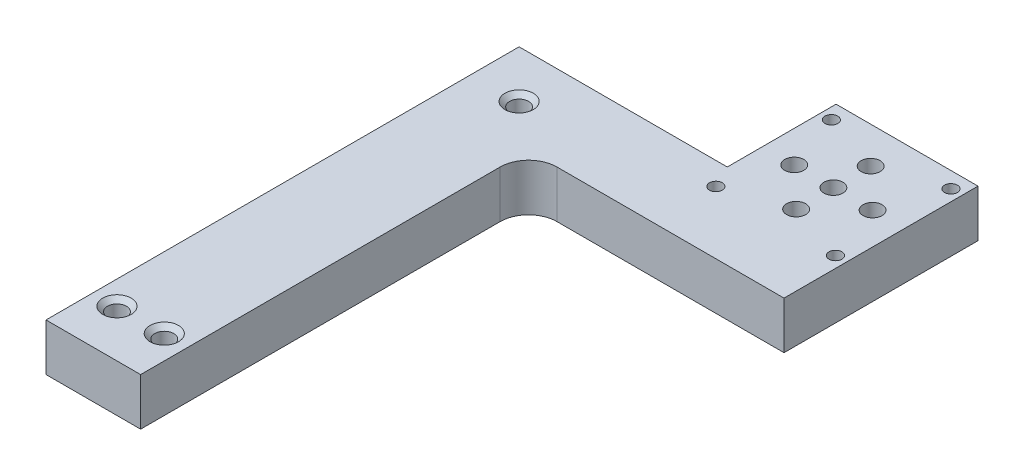
from build123d import *

# Parameters (mm, degrees)
BOSS_EXTRUDE1_DEPTH               = 12.7
F_1_4_20_TAPPED_HOLE1_D           = 5.1054
F_1_4_20_TAPPED_HOLE1_DEPTH       = 12.7
F_1_4_20_TAPPED_HOLE1_CSINK_D     = 7.62
F_1_4_20_TAPPED_HOLE1_CSINK_ANGLE = 90
F_1_4_20_TAPPED_HOLE2_D           = 5.1054
F_1_4_20_TAPPED_HOLE2_DEPTH       = 12.7
F_1_4_20_TAPPED_HOLE2_CSINK_D     = 7.62
F_1_4_20_TAPPED_HOLE2_CSINK_ANGLE = 90
F_29_0_136_DIAMETER_HOLE1_D       = 3.4544
F_29_0_136_DIAMETER_HOLE1_DEPTH   = 12.7
F_1_4_20_TAPPED_HOLE4_D           = 5.1054
F_1_4_20_TAPPED_HOLE4_DEPTH       = 12.7
LPATTERN1_COUNT                   = 3
LPATTERN1_PITCH                   = 10
F_1_4_20_TAPPED_HOLE6_D           = 5.1054
F_1_4_20_TAPPED_HOLE6_DEPTH       = 12.7
FILLET1_R                         = 7.62


with BuildPart() as part:
    # Sketch1 → Boss-Extrude1 (new body)
    with BuildSketch(Plane(origin=(0, 0, 0), x_dir=(1, 0, 0), z_dir=(0, 1, 0))):
        Polygon((81.28, 40.64), (81.28, 92.71), (43.18, 92.71), (43.18, 63.5), (12.7, 63.5), (-12.7, 63.5), (-12.7, -63.5), (12.7, -63.5), (12.7, 40.64), align=None)
    extrude(amount=BOSS_EXTRUDE1_DEPTH)

    # 1/4-20 Tapped Hole1
    with Locations(Plane(origin=(0, 12.7, 0), x_dir=(1, 0, 0), z_dir=(0, 1, 0))):
        with Locations((-6.35, -50.8), (6.35, -50.8)):
            CounterSinkHole(F_1_4_20_TAPPED_HOLE1_D / 2, F_1_4_20_TAPPED_HOLE1_CSINK_D / 2, depth=F_1_4_20_TAPPED_HOLE1_DEPTH, counter_sink_angle=F_1_4_20_TAPPED_HOLE1_CSINK_ANGLE)

    # 1/4-20 Tapped Hole2
    with Locations(Plane(origin=(0, 12.7, 0), x_dir=(1, 0, 0), z_dir=(0, 1, 0))):
        with Locations((0, 50.8)):
            CounterSinkHole(F_1_4_20_TAPPED_HOLE2_D / 2, F_1_4_20_TAPPED_HOLE2_CSINK_D / 2, depth=F_1_4_20_TAPPED_HOLE2_DEPTH, counter_sink_angle=F_1_4_20_TAPPED_HOLE2_CSINK_ANGLE)

    # #29 (0.136) Diameter Hole1
    with Locations(Plane(origin=(0, 12.7, 0), x_dir=(1, 0, 0), z_dir=(0, 1, 0))):
        with Locations((46.18, 88.44), (78.28, 88.44), (46.18, 57.44), (78.28, 57.44)):
            Hole(F_29_0_136_DIAMETER_HOLE1_D / 2, depth=F_29_0_136_DIAMETER_HOLE1_DEPTH)

    # 1/4-20 Tapped Hole4
    with Locations(Plane(origin=(0, 12.7, 0), x_dir=(1, 0, 0), z_dir=(0, 1, 0))):
        with Locations((62.23, 82.94)):
            f_1_4_20_tapped_hole4 = Hole(F_1_4_20_TAPPED_HOLE4_D / 2, depth=F_1_4_20_TAPPED_HOLE4_DEPTH)

    # LPattern1: 1/4-20 Tapped Hole4 ×3
    with Locations(*[(0, 0, i * LPATTERN1_PITCH) for i in range(1, LPATTERN1_COUNT)]):
        add(f_1_4_20_tapped_hole4, mode=Mode.SUBTRACT)

    # 1/4-20 Tapped Hole6
    with Locations(Plane(origin=(0, 12.7, 0), x_dir=(1, 0, 0), z_dir=(0, 1, 0))):
        with Locations((51.68, 72.972413119), (72.71230772, 72.972413119)):
            Hole(F_1_4_20_TAPPED_HOLE6_D / 2, depth=F_1_4_20_TAPPED_HOLE6_DEPTH)

    # Fillet1
    fillet1_edges = [part.edges().sort_by_distance(p)[0] for p in [
        (12.7, 6.35, -40.64),
    ]]
    fillet(fillet1_edges, radius=FILLET1_R)


solid = part.part
